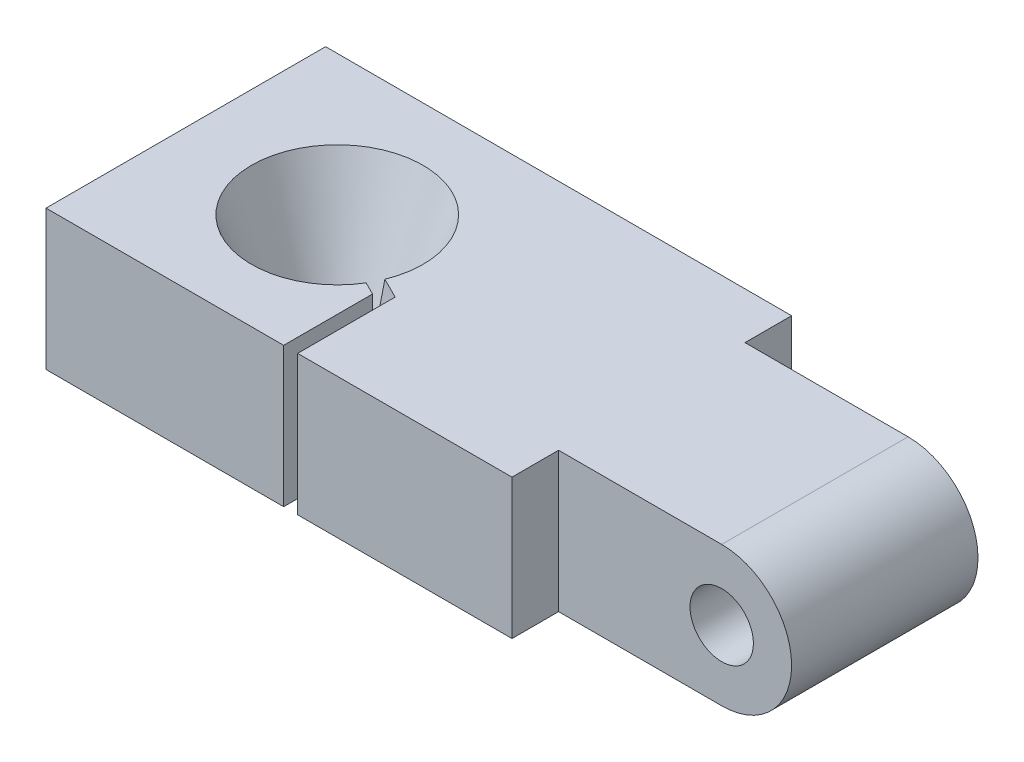
from build123d import *

# Parameters (mm, degrees)
BOSS_EXTRUDE1_DEPTH   = 10.16
F_4_CLEARANCE_HOLE1_D = 3.4544
SKETCH4_R             = 1.905
CUT_EXTRUDE1_DEPTH    = 8.62
CUT_EXTRUDE1_TAPER    = -20
SKETCH5_R             = 4.1275
CUT_EXTRUDE2_DEPTH    = 1.27
SKETCH6_W             = 25.4
SKETCH6_H             = 2.54
BOSS_EXTRUDE2_DEPTH   = 7.62
CUT_EXTRUDE3_DEPTH    = 8.62


with BuildPart() as part:
    # Sketch1 → Boss-Extrude1 (new body)
    with BuildSketch(Plane.XY):
        with BuildLine():
            Line((-17.145, -3.81), (17.145, -3.81))
            ThreePointArc((17.145, -3.81), (20.955, 0), (17.145, 3.81))
            Line((17.145, 3.81), (-17.145, 3.81))
            Line((-17.145, 3.81), (-17.145, -3.81))
        make_face()
    extrude(amount=BOSS_EXTRUDE1_DEPTH)

    # #4 Clearance Hole1 (through all)
    with Locations(Plane.XY.offset(10.16)):
        with Locations((17.145, 0)):
            Hole(F_4_CLEARANCE_HOLE1_D / 2)

    # Sketch4 → Cut-Extrude1 (cut, through all)
    with BuildSketch(Plane(origin=(0, -3.81, 0), x_dir=(1, 0, 0), z_dir=(0, 1, 0))):
        with Locations((-8.89, -5.08)):
            Circle(SKETCH4_R)
    extrude(amount=CUT_EXTRUDE1_DEPTH, taper=CUT_EXTRUDE1_TAPER, mode=Mode.SUBTRACT)

    # Sketch5 → Cut-Extrude2 (cut)
    with BuildSketch(Plane.XZ.offset(3.81)):
        with Locations((-8.89, 5.08)):
            Circle(SKETCH5_R)
    extrude(amount=-CUT_EXTRUDE2_DEPTH, mode=Mode.SUBTRACT)

    # Sketch6 → Boss-Extrude2 (add, through all)
    with BuildSketch(Plane.XZ.offset(3.81)):
        with Locations((-4.445, 11.43)):
            Rectangle(SKETCH6_W, SKETCH6_H)
        with Locations((-4.445, -1.27)):
            Rectangle(SKETCH6_W, SKETCH6_H)
    extrude(amount=-BOSS_EXTRUDE2_DEPTH)

    # Sketch8 → Cut-Extrude3 (cut, through all)
    with BuildSketch(Plane(origin=(0, 3.81, 0), x_dir=(1, 0, 0), z_dir=(0, 1, 0))):
        Polygon((-3.429, -12.7), (-3.429, -7.38452905), (-8.71961162, -4.73922324), (-9.06038838, -5.42077676), (-4.191, -7.85547095), (-4.191, -12.7), align=None)
    extrude(amount=-CUT_EXTRUDE3_DEPTH, mode=Mode.SUBTRACT)


solid = part.part
